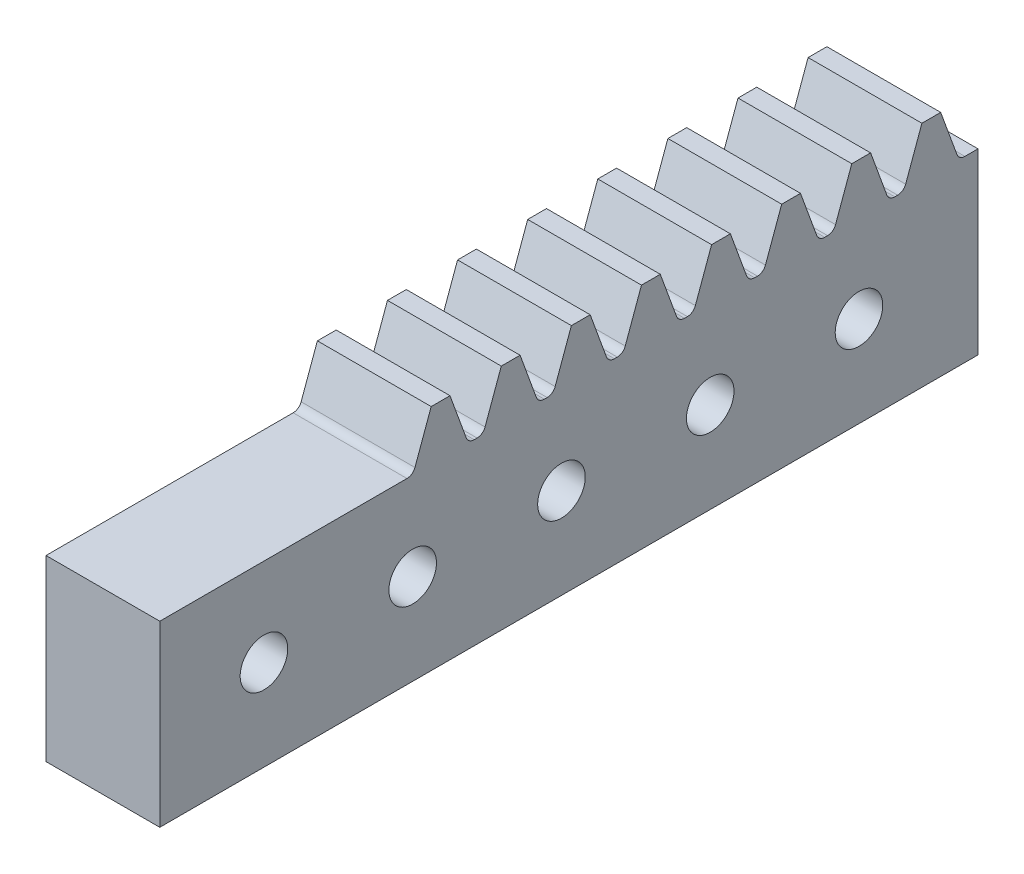
from build123d import *

# Parameters (mm, degrees)
ESQUISSE1_W                 = 24
ESQUISSE1_H                 = 30
MAIN_EXTRUSION_DEPTH        = 30
MAIN_RIDING_HOLE_DEPTH      = 36.623026261
ESQUISSE4_R                 = 2.25
TRACTORHOLE_DEPTH           = 8
IMPACTPIECE_DEPTH           = 4.5
CONG_1_R                    = 3
TEETH_DEPTH                 = 4.5
CONG_3_R                    = 0.57
TEETHREPETITION_COUNT       = 8
TEETHREPETITION_PITCH       = 4.71238898
CONG_3_OF_TEETHREPETITION_R = 0.57
ESQUISSE9_W                 = 55
ESQUISSE9_H                 = 15.375
BRACKET_DEPTH               = 0.675
ESQUISSE10_R                = 1.6
BRACKETHOLE_DEPTH           = 60.348546739
BRACKETHOLEREPETITION_COUNT = 5
BRACKETHOLEREPETITION_PITCH = 10
ESQUISSE11_W                = 7.5
ESQUISSE11_H                = 5.5
ESQUISSE11_H_2              = 7.6
RAILHOLE_DEPTH              = 20
TOPIMPACTCUT_DEPTH          = 60.348546739
ESQUISSE13_W                = 24
ESQUISSE13_H                = 50
MAKERBEAMMAINHOLE_DEPTH     = 95.451045521
KEEPONLYTRACTOR1_DEPTH      = 77.295478241
SKETCH2_W                   = 20
SKETCH2_H                   = 5.6
KEEPONLYTRACTOR2_DEPTH      = 41.263670039


with BuildPart() as part:
    # Esquisse1 → Main Extrusion (new body)
    with BuildSketch(Plane.XY):
        Rectangle(ESQUISSE1_W, ESQUISSE1_H)
    extrude(amount=MAIN_EXTRUSION_DEPTH)

    # Esquisse3 → Main Riding Hole (cut, through all)
    with BuildSketch(Plane(origin=(0, 0, 0), x_dir=(-1, 0, 0), z_dir=(0, 0, -1))):
        Polygon((-5.2, -1.6), (-5.2, -5.4), (-4.2, -5.4), (-4.2, -8.2), (-5.2, -8.2), (-5.2, -12), (-1.4, -12), (-1.4, -11), (1.4, -11), (1.4, -12), (5.2, -12), (5.2, -8.2), (4.2, -8.2), (4.2, -5.4), (5.2, -5.4), (5.2, -1.6), (1.4, -1.6), (1.4, -2.6), (-1.4, -2.6), (-1.4, -1.6), align=None)
    extrude(amount=-MAIN_RIDING_HOLE_DEPTH, mode=Mode.SUBTRACT)

    # Esquisse4 → TractorHole (cut)
    with BuildSketch(Plane.ZY.offset(12)):
        with Locations(Location((5, -6.8, 0), (0, 0, 270))):
            Circle(ESQUISSE4_R)
    tractorhole = extrude(amount=-TRACTORHOLE_DEPTH, mode=Mode.SUBTRACT)

    # TractorHoleSymetry: TractorHole across plane
    add(tractorhole.mirror(Plane(origin=(0, 0, 0), x_dir=(0, 0, 1), z_dir=(1, 0, 0))), mode=Mode.SUBTRACT)

    # Esquisse5 → ImpactPiece (add, symmetric)
    with BuildSketch(Plane(origin=(0, 0, 0), x_dir=(0, 0, -1), z_dir=(1, 0, 0))):
        Polygon((-45, 5), (-45, 35), (-25, 35), (-21.473460386, 15), (35, 15), (35, 3), (0, 3), (0, 5), align=None)
    extrude(amount=IMPACTPIECE_DEPTH, both=True)

    # Congé1
    cong_1_edges = [part.edges().sort_by_distance(p)[0] for p in [
        (4.5, 15, 25.736730193),
        (-4.5, 15, 25.736730193),
    ]]
    fillet(cong_1_edges, radius=CONG_1_R)

    # Esquisse8 → Teeth (add, symmetric)
    with BuildSketch(Plane(origin=(0, 0, 0), x_dir=(0, 0, -1), z_dir=(1, 0, 0))):
        Polygon((30, 15), (31.228399541, 18.375), (32.492683328, 18.375), (33.721082869, 15), align=None)
    teeth = extrude(amount=TEETH_DEPTH, both=True)

    # Congé3
    cong_3_edges = [part.edges().sort_by_distance(p)[0] for p in [
        (0, 15, -30),
        (0, 15, -33.721082869),
    ]]
    fillet(cong_3_edges, radius=CONG_3_R)

    # TeethRepetition: Teeth ×8
    with Locations(*[(0, 0, i * TEETHREPETITION_PITCH) for i in range(1, TEETHREPETITION_COUNT)]):
        add(teeth)

    # Congé3 of TeethRepetition
    cong_3_of_teethrepetition_edges = [part.edges().sort_by_distance(p)[0] for p in [
        (0, 15, -25.28761102),
        (0, 15, -29.008693889),
        (0, 15, -20.57522204),
        (0, 15, -24.296304909),
        (0, 15, -15.86283306),
        (0, 15, -19.583915929),
        (0, 15, -11.15044408),
        (0, 15, -14.871526949),
        (0, 15, -6.4380551),
        (0, 15, -10.159137969),
        (0, 15, -1.72566612),
        (0, 15, -5.446748989),
        (0, 15, 2.98672286),
        (0, 15, -0.734360009),
    ]]
    fillet(cong_3_of_teethrepetition_edges, radius=CONG_3_OF_TEETHREPETITION_R)

    # Esquisse9 → Bracket (cut, symmetric)
    with BuildSketch(Plane(origin=(4.5, 0, 0), x_dir=(0, 0, -1), z_dir=(1, 0, 0))):
        with Locations((7.5, 10.6875)):
            Rectangle(ESQUISSE9_W, ESQUISSE9_H)
    bracket = extrude(amount=BRACKET_DEPTH, both=True, mode=Mode.SUBTRACT)

    # Esquisse10 → BracketHole (cut, symmetric)
    with BuildSketch(Plane.ZY.offset(-4.5)):
        with Locations((-27, 9.1)):
            Circle(ESQUISSE10_R)
    brackethole = extrude(amount=BRACKETHOLE_DEPTH, both=True, mode=Mode.SUBTRACT)

    # BracketHoleRepetition: BracketHole ×5
    with Locations(*[(0, 0, i * BRACKETHOLEREPETITION_PITCH) for i in range(1, BRACKETHOLEREPETITION_COUNT)]):
        add(brackethole, mode=Mode.SUBTRACT)

    # Symétrie1: Bracket across plane
    add(bracket.mirror(Plane(origin=(0, 0, 0), x_dir=(0, 0, 1), z_dir=(1, 0, 0))), mode=Mode.SUBTRACT)

    # Esquisse11 → RailHole (cut)
    with BuildSketch(Plane(origin=(0, 0, 0), x_dir=(-1, 0, 0), z_dir=(0, 0, -1))):
        with Locations((8.25, 3.15)):
            Rectangle(ESQUISSE11_W, ESQUISSE11_H)
        with Locations((8.25, 16.2)):
            Rectangle(ESQUISSE11_W, ESQUISSE11_H_2)
    extrude(amount=-RAILHOLE_DEPTH, mode=Mode.SUBTRACT)

    # Esquisse12 → TopImpactCut (cut, through all)
    with BuildSketch(Plane(origin=(4.5, 0, 0), x_dir=(0, 0, -1), z_dir=(1, 0, 0))):
        Polygon((-45, 30), (-40, 35), (-45, 35), align=None)
    extrude(amount=-TOPIMPACTCUT_DEPTH, mode=Mode.SUBTRACT)


with BuildPart() as body_2:
    # Symétrie2: mirrored copy
    add(part.part.mirror(Plane(origin=(12, 15, 30), x_dir=(0, 0, 1), z_dir=(-1, 0, 0))))

    # Sketch1 → KeepOnlyTractor1 (cut, through all)
    with BuildSketch(Plane(origin=(0, 35, 0), x_dir=(1, 0, 0), z_dir=(0, 1, 0))):
        Polygon((12, 0), (12, -45), (36, -45), (36, 0), (27.825, 0.05190699), (27.825, -20), (20.175, -20), (20.175, 0), align=None)
    extrude(amount=-KEEPONLYTRACTOR1_DEPTH, mode=Mode.SUBTRACT)


with BuildPart() as part_1:
    add(part.part)

    # Esquisse13 → MakerBeamMainHole (cut, through all)
    with BuildSketch(Plane(origin=(0, 0, -35), x_dir=(-1, 0, 0), z_dir=(0, 0, -1))):
        with Locations((0, 10)):
            Rectangle(ESQUISSE13_W, ESQUISSE13_H)
    extrude(amount=-MAKERBEAMMAINHOLE_DEPTH, mode=Mode.SUBTRACT)


with BuildPart() as keeponlytractor1_kept_piece:
    # of the separate pieces the step leaves, the one the design keeps (keeponlytractor1_pieces_kept)
    add(body_2.part.solids().sort_by_distance((27.825, 15, 3.385841157))[0])

    # Sketch2 → KeepOnlyTractor2 (cut, through all)
    with BuildSketch(Plane.ZY.offset(-20.175)):
        with Locations((10, 0.2)):
            Rectangle(SKETCH2_W, SKETCH2_H)
    extrude(amount=-KEEPONLYTRACTOR2_DEPTH, mode=Mode.SUBTRACT)


solid = keeponlytractor1_kept_piece.part
